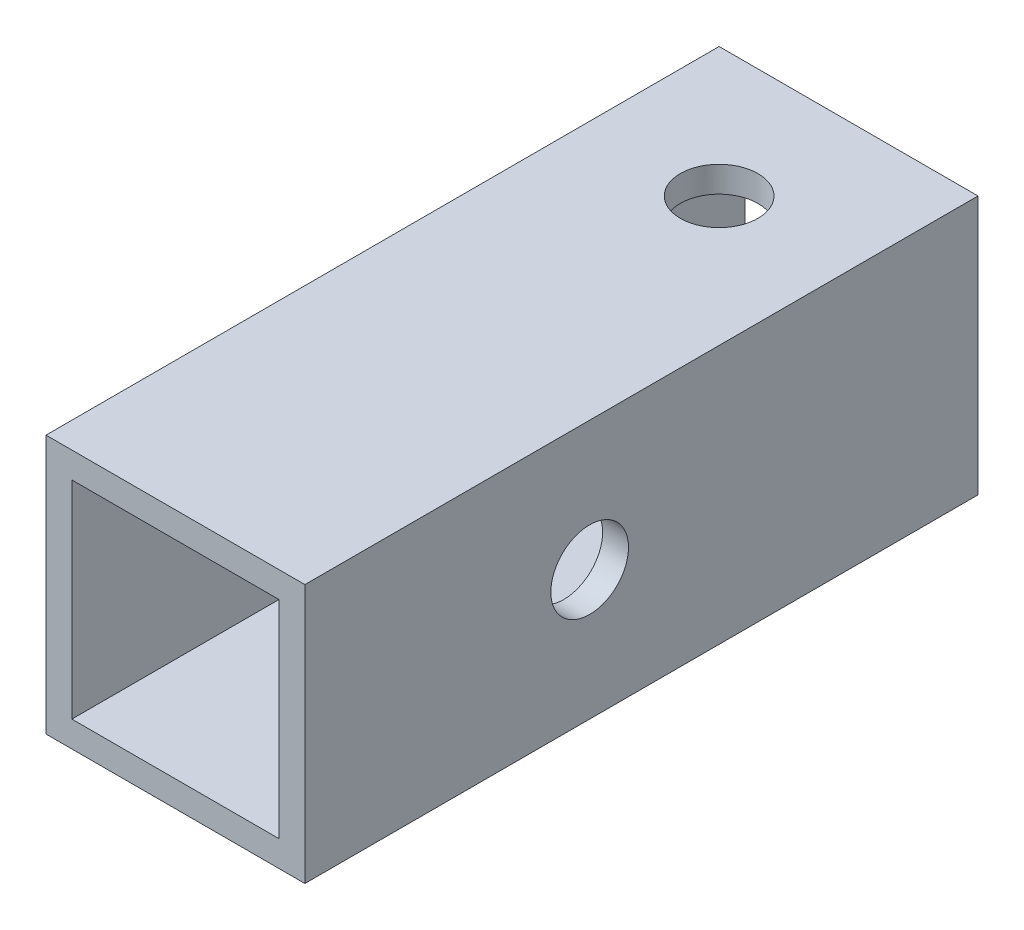
from build123d import *

# Parameters (mm, degrees)
SKETCH_1_W          = 10
SKETCH_1_H          = 10
SKETCH_1_W_2        = 8
SKETCH_1_H_2        = 8
EXTRUDE_1_DEPTH     = 26
SKETCH_2_R          = 1.5
CUT_EXTRUDE_1_DEPTH = 50
SKETCH_3_R          = 1.5
CUT_EXTRUDE_2_DEPTH = 10


with BuildPart() as part:
    # 草图1 → 拉伸-薄壁1 (new body)
    with BuildSketch(Plane.XY):
        Rectangle(SKETCH_1_W, SKETCH_1_H)
        Rectangle(SKETCH_1_W_2, SKETCH_1_H_2, mode=Mode.SUBTRACT)
    extrude(amount=EXTRUDE_1_DEPTH)

    # 草图2 → 切除-拉伸1 (cut)
    with BuildSketch(Plane(origin=(0, 5, 0), x_dir=(1, 0, 0), z_dir=(0, 1, 0))):
        with Locations((0, -5)):
            Circle(SKETCH_2_R)
    extrude(amount=-CUT_EXTRUDE_1_DEPTH, mode=Mode.SUBTRACT)

    # 草图3 → 切除-拉伸2 (cut)
    with BuildSketch(Plane(origin=(5, 0, 0), x_dir=(0, 0, -1), z_dir=(1, 0, 0))):
        with Locations((-15, 0)):
            Circle(SKETCH_3_R)
    extrude(amount=-CUT_EXTRUDE_2_DEPTH, mode=Mode.SUBTRACT)


solid = part.part
